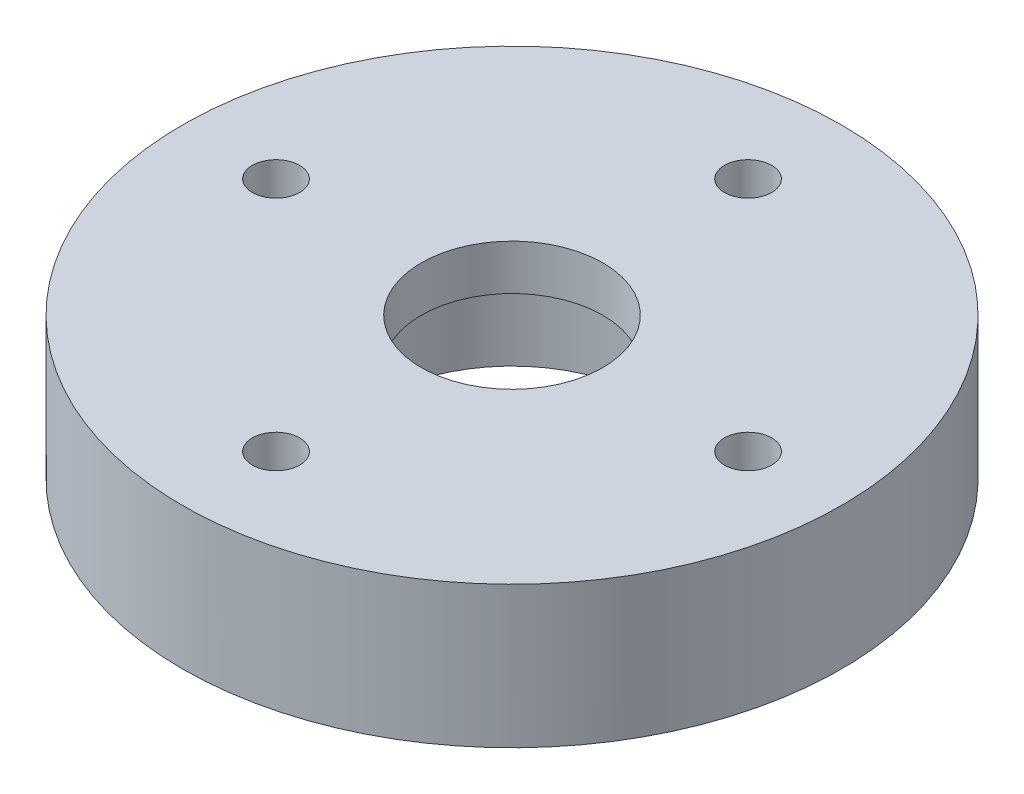
from build123d import *

# Parameters (mm, degrees)
SKETCH_1_R               = 18.15
SKETCH_1_R_2             = 7.6
EXTRUDE_1_DEPTH          = 5.3
SKETCH_8_R               = 18.15
SKETCH_8_R_2             = 5
EXTRUDE_6_DEPTH          = 2.5
SKETCH_9_R               = 1.3
CUT_EXTRUDE_3_DEPTH      = 8.8
PATTERN_CIRCULAR_1_COUNT = 4


with BuildPart() as part:
    # Эскиз1 → Бобышка-Вытянуть1 (new body)
    with BuildSketch(Plane(origin=(0, 0, 0), x_dir=(1, 0, 0), z_dir=(0, 1, 0))):
        Circle(SKETCH_1_R)
        Circle(SKETCH_1_R_2, mode=Mode.SUBTRACT)
    extrude(amount=EXTRUDE_1_DEPTH)

    # Эскиз8 → Бобышка-Вытянуть6 (add)
    with BuildSketch(Plane.XZ.offset(-5.3)):
        Circle(SKETCH_8_R)
        Circle(SKETCH_8_R_2, mode=Mode.SUBTRACT)
    extrude(amount=-EXTRUDE_6_DEPTH)

    # Эскиз9 → Вырез-Вытянуть3 (cut, through all)
    with BuildSketch(Plane(origin=(0, 7.8, 0), x_dir=(1, 0, 0), z_dir=(0, 1, 0))):
        with Locations((0, 13)):
            Circle(SKETCH_9_R)
    cut_extrude_3 = extrude(amount=-CUT_EXTRUDE_3_DEPTH, mode=Mode.SUBTRACT)

    # Круговой массив1: Вырез-Вытянуть3 ×4 about axis
    pattern_circular_1_axis = Axis((0, 0, 0), (0, 1, 0))
    for i in range(1, PATTERN_CIRCULAR_1_COUNT):
        add(cut_extrude_3.rotate(pattern_circular_1_axis, i * 360 / PATTERN_CIRCULAR_1_COUNT), mode=Mode.SUBTRACT)


solid = part.part
